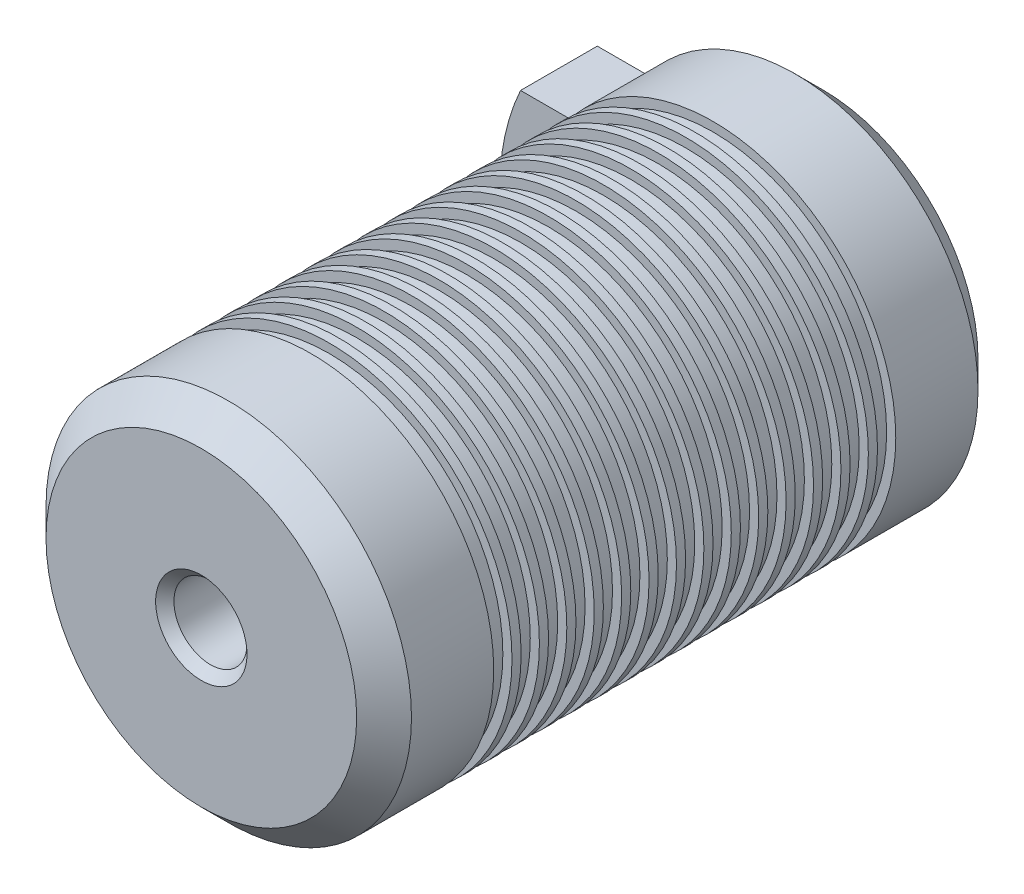
from build123d import *

# Parameters (mm, degrees)
SKETCH1_R                       = 20
BOSS_EXTRUDE1_DEPTH             = 68
SKETCH2_R                       = 4
CUT_EXTRUDE1_DEPTH              = 10
CHAMFER1_SIZE                   = 3
CUT_EXTRUDE3_START              = -12
SKETCH5_R                       = 20
SKETCH5_R_2                     = 19
CUT_EXTRUDE3_DEPTH              = 2
LPATTERN1_COUNT                 = 15
LPATTERN1_PITCH                 = 3
CHAMFER2_SIZE                   = 1
BOSS_EXTRUDE2_REACH             = 83.388
BOSS_EXTRUDE2_END_RADIUS        = 20
SKETCH6_W                       = 8.4
SKETCH6_H                       = 10.5
BOSS_EXTRUDE2_DIRECTION_2_DEPTH = 5.5
CUT_EXTRUDE4_DEPTH              = 10.1


with BuildPart() as part:
    # Sketch1 → Boss-Extrude1 (new body)
    with BuildSketch(Plane.XY):
        Circle(SKETCH1_R)
    extrude(amount=BOSS_EXTRUDE1_DEPTH)

    # Sketch2 → Cut-Extrude1 (cut)
    with BuildSketch(Plane.XY.offset(68)):
        Circle(SKETCH2_R)
    extrude(amount=-CUT_EXTRUDE1_DEPTH, mode=Mode.SUBTRACT)

    # Chamfer1
    chamfer1_edges = [part.edges().sort_by_distance(p)[0] for p in [
        (-20, 0, 0),
        (-20, 0, 68),
    ]]
    chamfer(chamfer1_edges, length=CHAMFER1_SIZE)

    # Sketch5 → Cut-Extrude3 (cut)
    with BuildSketch(Plane.XY.offset(68).offset(CUT_EXTRUDE3_START)):
        Circle(SKETCH5_R)
        Circle(SKETCH5_R_2, mode=Mode.SUBTRACT)
    cut_extrude3 = extrude(amount=-CUT_EXTRUDE3_DEPTH, mode=Mode.SUBTRACT)

    # LPattern1: Cut-Extrude3 ×15
    with Locations(*[(0, 0, -i * LPATTERN1_PITCH) for i in range(1, LPATTERN1_COUNT)]):
        add(cut_extrude3, mode=Mode.SUBTRACT)

    # Chamfer2
    chamfer2_edges = [part.edges().sort_by_distance(p)[0] for p in [
        (-4, 0, 68),
    ]]
    chamfer(chamfer2_edges, length=CHAMFER2_SIZE)

    # Boss-Extrude2: up to this cylinder (the profile starts outside it)
    boss_extrude2_end = Plane(origin=(0, 0, 5.9), z_dir=(0, 0, -1)) * Cylinder(BOSS_EXTRUDE2_END_RADIUS, 207.776, mode=Mode.PRIVATE)
    # Sketch6 → Boss-Extrude2 (add, up to the surface)
    with BuildSketch(Plane.ZY.offset(20), mode=Mode.PRIVATE) as boss_extrude2_sk1:
        with Locations((5.9, 5.25)):
            Rectangle(SKETCH6_W, SKETCH6_H)
    boss_extrude2_tool1 = extrude(boss_extrude2_sk1.sketch, amount=-BOSS_EXTRUDE2_REACH, mode=Mode.PRIVATE) - boss_extrude2_end
    add(boss_extrude2_tool1.solids().sort_by_distance((-20, 5.25, 5.9))[0])
    # Sketch6 → Boss-Extrude2 (add, up to the surface)
    with BuildSketch(Plane.ZY.offset(20), mode=Mode.PRIVATE) as boss_extrude2_sk2:
        with Locations((5.9, -5.25)):
            Rectangle(SKETCH6_W, SKETCH6_H)
    boss_extrude2_tool2 = extrude(boss_extrude2_sk2.sketch, amount=-BOSS_EXTRUDE2_REACH, mode=Mode.PRIVATE) - boss_extrude2_end
    add(boss_extrude2_tool2.solids().sort_by_distance((-20, -5.25, 5.9))[0])

    # Sketch6 → Boss-Extrude2 direction 2 (add)
    with BuildSketch(Plane.ZY.offset(20)):
        with Locations((5.9, 5.25)):
            Rectangle(SKETCH6_W, SKETCH6_H)
        with Locations((5.9, -5.25)):
            Rectangle(SKETCH6_W, SKETCH6_H)
    extrude(amount=BOSS_EXTRUDE2_DIRECTION_2_DEPTH)

    # Sketch7 → Cut-Extrude4 (cut)
    with BuildSketch(Plane.XY):
        with BuildLine():
            Line((-22.963285915, 10.5), (-25.5, 10.5))
            Line((-25.5, 10.5), (-25.5, 0))
            Line((-25.5, 0), (-25.25, 0))
            ThreePointArc((-25.25, 0), (-24.671699063, 5.373059215), (-22.963285915, 10.5))
        make_face()
        with BuildLine():
            Line((-25.25, 0), (-25.5, 0))
            Line((-25.5, 0), (-25.5, -10.5))
            Line((-25.5, -10.5), (-22.963285915, -10.5))
            ThreePointArc((-22.963285915, -10.5), (-24.671699063, -5.373059215), (-25.25, 0))
        make_face()
    extrude(amount=CUT_EXTRUDE4_DEPTH, mode=Mode.SUBTRACT)


solid = part.part
